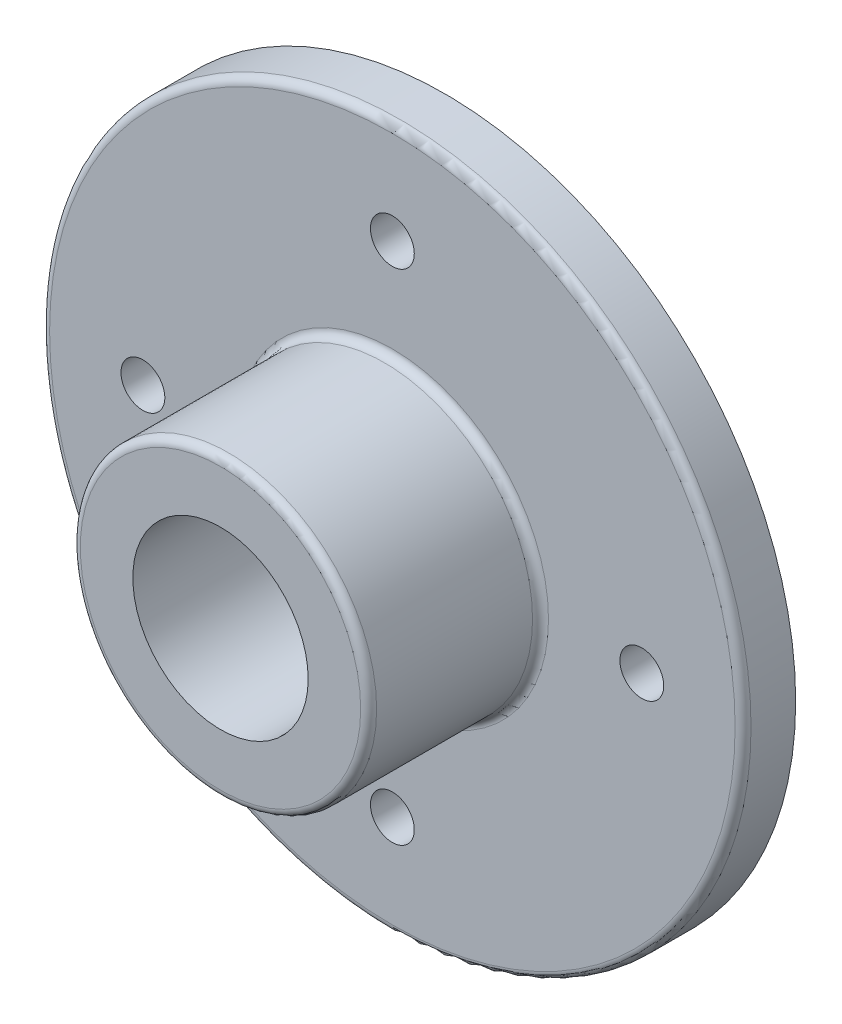
from build123d import *

# Parameters (mm, degrees)
SKETCH1_R         = 50.8
EXTRUDE1_DEPTH    = 7.62
SKETCH2_R         = 21.463
EXTRUDE2_DEPTH    = 24.892
SKETCH3_R         = 3.175
EXTRUDE3_DEPTH    = 8.62
CIRPATTERN1_COUNT = 4
FILLET1_R         = 1.154545455
SKETCH4_W         = 79.017488084
SKETCH4_H         = 12.7


with BuildPart() as part:
    # Sketch1 → Extrude1 (new body)
    with BuildSketch(Plane.XY):
        Circle(SKETCH1_R)
    extrude(amount=EXTRUDE1_DEPTH)

    # Sketch2 → Extrude2 (add)
    with BuildSketch(Plane.XY.offset(7.62)):
        Circle(SKETCH2_R)
    extrude(amount=EXTRUDE2_DEPTH)

    # Sketch3 → Extrude3 (cut, through all)
    with BuildSketch(Plane.XY.offset(7.62)):
        with Locations((0, 36.1315)):
            Circle(SKETCH3_R)
    extrude3 = extrude(amount=-EXTRUDE3_DEPTH, mode=Mode.SUBTRACT)

    # CirPattern1: Extrude3 ×4 about axis
    cirpattern1_axis = Axis((0, 0, 0), (0, 0, 1))
    for i in range(1, CIRPATTERN1_COUNT):
        add(extrude3.rotate(cirpattern1_axis, i * 360 / CIRPATTERN1_COUNT), mode=Mode.SUBTRACT)

    # Fillet1
    fillet1_edges = [part.edges().sort_by_distance(p)[0] for p in [
        (-50.8, 0, 7.62),
        (-21.463, 0, 7.62),
        (-21.463, 0, 32.512),
    ]]
    fillet(fillet1_edges, radius=FILLET1_R)

    # Sketch4 → Cut-Revolve1 (revolve, cut)
    with BuildSketch(Plane(origin=(0, 0, 63.5), x_dir=(0, 0, -1), z_dir=(1, 0, 0))):
        with Locations((39.507700489, 6.35)):
            Rectangle(SKETCH4_W, SKETCH4_H)
    revolve(axis=Axis((0, 0, -15.516444531), (0, 0, 1)), mode=Mode.SUBTRACT)


solid = part.part
